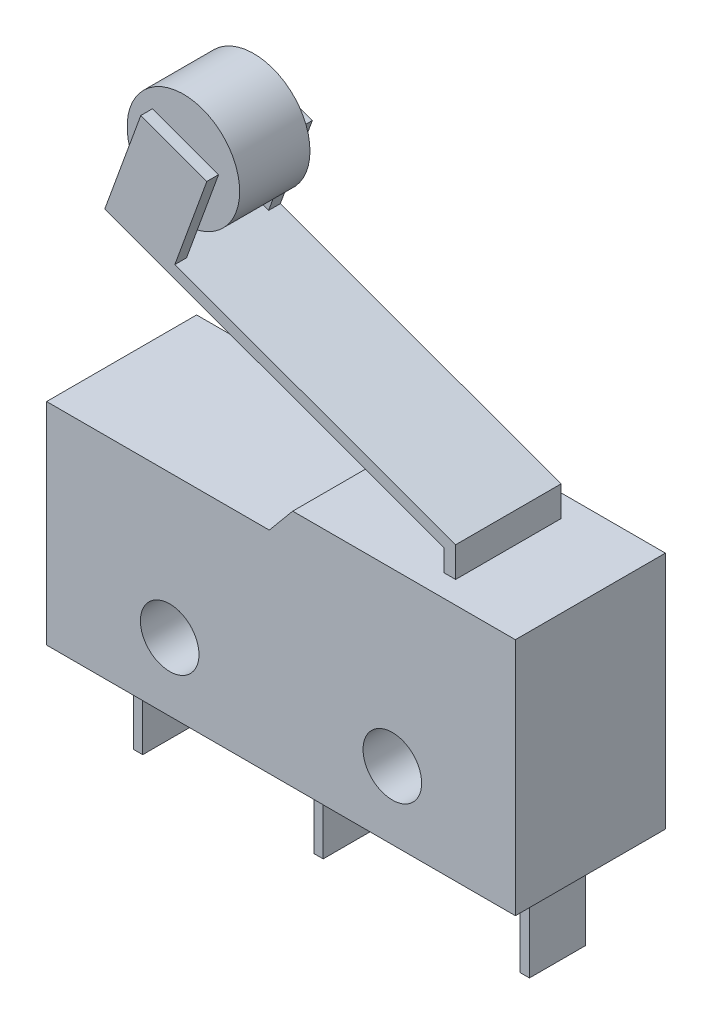
from build123d import *

# Parameters (mm, degrees)
CROQUIS1_R              = 1.25
SALIENTE_EXTRUIR1_DEPTH = 3.2
CROQUIS2_W              = 0.4
CROQUIS2_H              = 2.4
SALIENTE_EXTRUIR2_DEPTH = 4
SALIENTE_EXTRUIR3_DEPTH = 2.25
CROQUIS4_W              = 3
CROQUIS4_H              = 0.5
SALIENTE_EXTRUIR4_DEPTH = 4
CROQUIS5_R              = 2.4
SALIENTE_EXTRUIR5_DEPTH = 1.5


with BuildPart() as part:
    # Croquis1 → Saliente-Extruir1 (new body, symmetric)
    with BuildSketch(Plane.XY):
        Polygon((0, 9), (9.5, 9), (10.5, 10.2), (20, 10.2), (20, 0), (0, 0), align=None)
        with Locations((5.25, 2.9)):
            Circle(CROQUIS1_R, mode=Mode.SUBTRACT)
        with Locations((14.75, 2.9)):
            Circle(CROQUIS1_R, mode=Mode.SUBTRACT)
    extrude(amount=SALIENTE_EXTRUIR1_DEPTH, both=True)

    # Croquis2 → Saliente-Extruir2 (add)
    with BuildSketch(Plane.XZ):
        with Locations((1.9, 0)):
            Rectangle(CROQUIS2_W, CROQUIS2_H)
        with Locations((9.6, 0)):
            Rectangle(CROQUIS2_W, CROQUIS2_H)
        with Locations((18.4, 0)):
            Rectangle(CROQUIS2_W, CROQUIS2_H)
    extrude(amount=SALIENTE_EXTRUIR2_DEPTH)

    # Croquis3 → Saliente-Extruir3 (add, symmetric)
    with BuildSketch(Plane.XY):
        Polygon((16, 10.2), (16, 11.133146081), (1.529437785, 16.4), (1.700447857, 16.86984631), (16.5, 11.48324985), (16.5, 10.2), align=None)
    extrude(amount=SALIENTE_EXTRUIR3_DEPTH, both=True)

    # Croquis4 → Saliente-Extruir4 (add)
    with BuildSketch(Plane(origin=(5.620778705, 15.442962573, 0), x_dir=(0.939692621, -0.342020143, 0), z_dir=(0.342020143, 0.939692621, 0))):
        with Locations((-2.67192895, 2)):
            Rectangle(CROQUIS4_W, CROQUIS4_H)
        with Locations((-2.67192895, -2)):
            Rectangle(CROQUIS4_W, CROQUIS4_H)
    extrude(amount=SALIENTE_EXTRUIR4_DEPTH)


with BuildPart() as body_2:
    # Croquis5 → Saliente-Extruir5 (new body, symmetric)
    with BuildSketch(Plane.XY):
        with Locations((4.136047218, 19.175893958)):
            Circle(CROQUIS5_R)
    extrude(amount=SALIENTE_EXTRUIR5_DEPTH, both=True)


solid = Compound([part.part, body_2.part])
